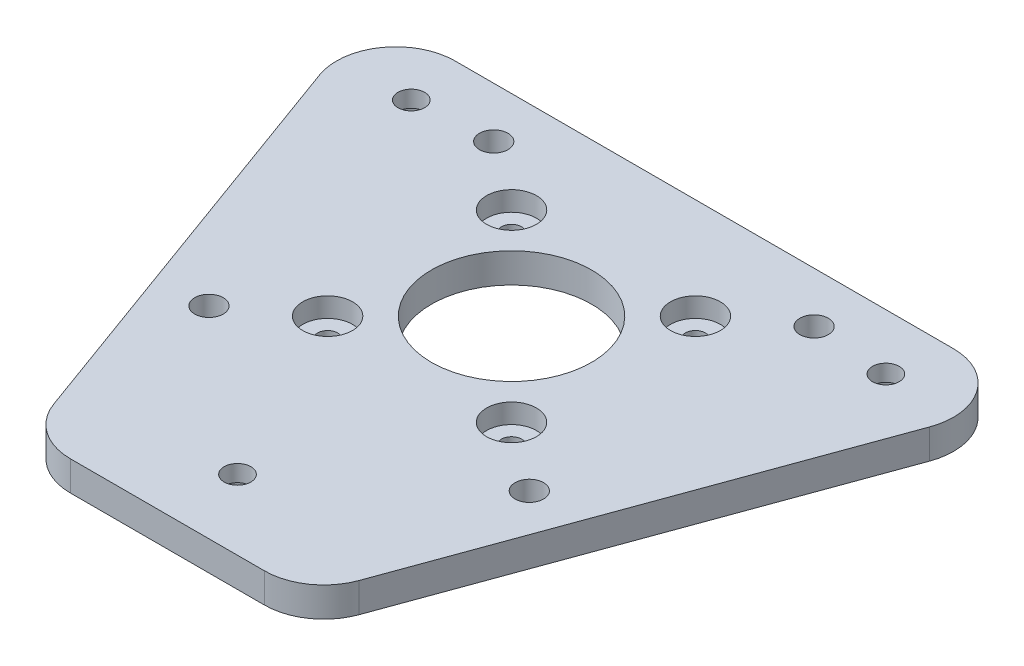
from build123d import *

# Parameters (mm, degrees)
SKETCH2_W                                        = 130
SKETCH2_H                                        = 130
BOSS_EXTRUDE1_DEPTH                              = 5
SKETCH3_R                                        = 13.5
CUT_EXTRUDE1_DEPTH                               = 5
SKETCH8_W                                        = 130
SKETCH8_H                                        = 130
CUT_EXTRUDE6_DEPTH                               = 6
M4_CLEARANCE_HOLE1_D                             = 4.8
M4_CLEARANCE_HOLE1_DEPTH                         = 5
CBORE_FOR_M3_HEX_HEAD_MACHINE_SCREW1_D           = 3.4
CBORE_FOR_M3_HEX_HEAD_MACHINE_SCREW1_DEPTH       = 5
CBORE_FOR_M3_HEX_HEAD_MACHINE_SCREW1_CBORE_D     = 8.4
CBORE_FOR_M3_HEX_HEAD_MACHINE_SCREW1_CBORE_DEPTH = 3.3
CBORE_FOR_M4_SBHCS1_D                            = 4.5
CBORE_FOR_M4_SBHCS1_DEPTH                        = 5
CBORE_FOR_M4_SBHCS1_CBORE_D                      = 8.6
CBORE_FOR_M4_SBHCS1_CBORE_DEPTH                  = 2.2


with BuildPart() as part:
    # Sketch2 → Boss-Extrude1 (new body)
    with BuildSketch(Plane(origin=(0, 0, 0), x_dir=(1, 0, 0), z_dir=(0, 1, 0))):
        Rectangle(SKETCH2_W, SKETCH2_H)
    extrude(amount=BOSS_EXTRUDE1_DEPTH)

    # Sketch3 → Cut-Extrude1 (cut)
    with BuildSketch(Plane(origin=(0, 5, 0), x_dir=(1, 0, 0), z_dir=(0, 1, 0))):
        Circle(SKETCH3_R)
    extrude(amount=-CUT_EXTRUDE1_DEPTH, mode=Mode.SUBTRACT)

    # Sketch8 → Cut-Extrude6 (cut, through all)
    with BuildSketch(Plane(origin=(0, 5, 0), x_dir=(1, 0, 0), z_dir=(0, 1, 0))):
        Rectangle(SKETCH8_W, SKETCH8_H)
        with BuildLine():
            Line((-42.00982343, 32.5), (42.00982343, 32.5))
            ThreePointArc((42.00982343, 32.5), (50.201409492, 28.235670649), (51.406671379, 19.079583559))
            Line((51.406671379, 19.079583559), (25.74494306, -51.420416441))
            ThreePointArc((25.74494306, -51.420416441), (22.083765761, -56.191586062), (16.348095112, -58))
            Line((16.348095112, -58), (-16.348095112, -58))
            ThreePointArc((-16.348095112, -58), (-22.083765761, -56.191586062), (-25.74494306, -51.420416441))
            Line((-25.74494306, -51.420416441), (-51.406671379, 19.079583559))
            ThreePointArc((-51.406671379, 19.079583559), (-50.201409492, 28.235670649), (-42.00982343, 32.5))
        make_face(mode=Mode.SUBTRACT)
    extrude(amount=-CUT_EXTRUDE6_DEPTH, mode=Mode.SUBTRACT)

    # M4 Clearance Hole1
    with Locations(Plane(origin=(0, 5, 0), x_dir=(1, 0, 0), z_dir=(0, 1, 0))):
        with Locations((-27, 24), (27, 24), (27, -24), (-27, -24)):
            Hole(M4_CLEARANCE_HOLE1_D / 2, depth=M4_CLEARANCE_HOLE1_DEPTH)

    # CBORE for M3 Hex Head Machine Screw1
    with Locations(Plane(origin=(0, 5, 0), x_dir=(1, 0, 0), z_dir=(0, 1, 0))):
        with Locations((-15.5, 15.5), (15.5, 15.5), (15.5, -15.5), (-15.5, -15.5)):
            CounterBoreHole(CBORE_FOR_M3_HEX_HEAD_MACHINE_SCREW1_D / 2, CBORE_FOR_M3_HEX_HEAD_MACHINE_SCREW1_CBORE_D / 2, CBORE_FOR_M3_HEX_HEAD_MACHINE_SCREW1_CBORE_DEPTH, depth=CBORE_FOR_M3_HEX_HEAD_MACHINE_SCREW1_DEPTH)

    # CBORE for M4 SBHCS1
    with Locations(Plane(origin=(0, 0, 0), x_dir=(-1, 0, 0), z_dir=(0, -1, 0))):
        with Locations((0, -46.19), (40, 23.1), (-40, 23.1)):
            CounterBoreHole(CBORE_FOR_M4_SBHCS1_D / 2, CBORE_FOR_M4_SBHCS1_CBORE_D / 2, CBORE_FOR_M4_SBHCS1_CBORE_DEPTH, depth=CBORE_FOR_M4_SBHCS1_DEPTH)


solid = part.part
